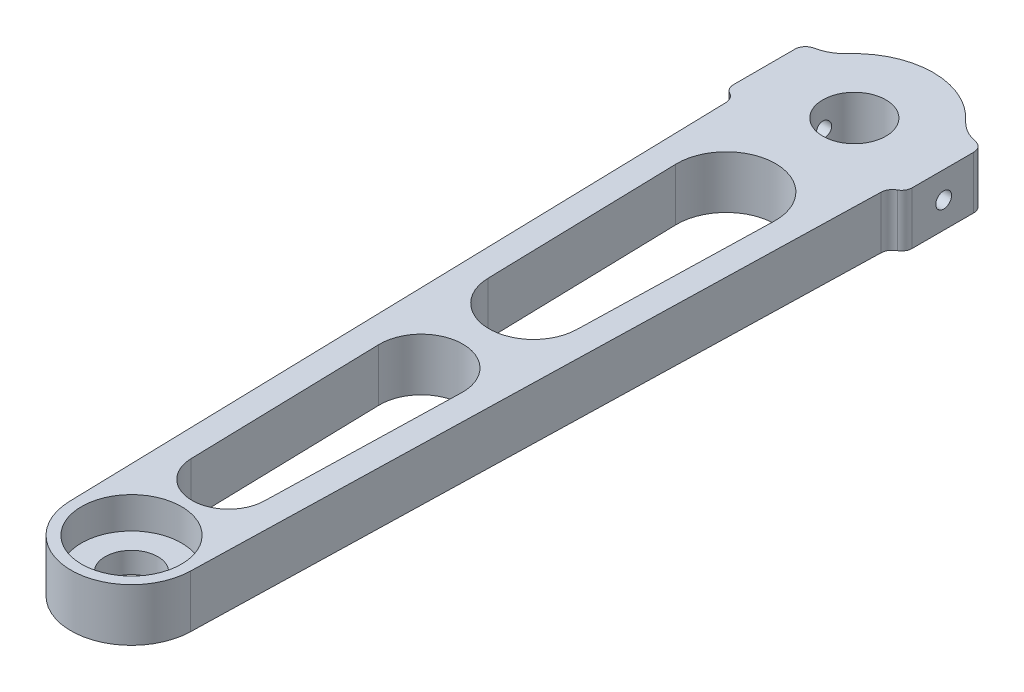
from build123d import *

# Parameters (mm, degrees)
SKETCH1_R           = 6
SKETCH1_R_2         = 5
BOSS_EXTRUDE1_DEPTH = 10
SKETCH2_R           = 9.5
CUT_EXTRUDE1_DEPTH  = 6
CUT_EXTRUDE3_DEPTH  = 11
FILLET1_R           = 2
M4_TAPPED_HOLE1_D   = 3


with BuildPart() as part:
    # Sketch1 → Boss-Extrude1 (new body)
    with BuildSketch(Plane(origin=(0, 0, 0), x_dir=(1, 0, 0), z_dir=(0, 1, 0))):
        with BuildLine():
            Line((-14.758368201, -9.680542044), (-11.496273776, -137.792727273))
            ThreePointArc((-11.496273776, -137.792727273), (0, -149), (11.496273776, -137.792727273))
            Line((11.496273776, -137.792727273), (14.758368201, -9.680542044))
            ThreePointArc((14.758368201, -9.680542044), (15.433257, -8.135337646), (16.995139708, -7.5))
            Line((16.995139708, -7.5), (16.995139708, 7.5))
            ThreePointArc((16.995139708, 7.5), (13.895638119, 8.122041636), (11.276155185, 9.891831188))
            ThreePointArc((11.276155185, 9.891831188), (0.004561048, 14.999999307), (-11.270137484, 9.898686836))
            ThreePointArc((-11.270137484, 9.898686836), (-13.891539017, 8.123905388), (-16.995139708, 7.5))
            Line((-16.995139708, 7.5), (-16.995139708, -7.5))
            ThreePointArc((-16.995139708, -7.5), (-15.433257, -8.135337646), (-14.758368201, -9.680542044))
        make_face()
        Circle(SKETCH1_R, mode=Mode.SUBTRACT)
        with Locations((0, -137.5)):
            Circle(SKETCH1_R_2, mode=Mode.SUBTRACT)
    extrude(amount=BOSS_EXTRUDE1_DEPTH)

    # Sketch2 → Cut-Extrude1 (cut)
    with BuildSketch(Plane(origin=(0, 10, 0), x_dir=(1, 0, 0), z_dir=(0, 1, 0))):
        with Locations((0, -137.5)):
            Circle(SKETCH2_R)
    extrude(amount=-CUT_EXTRUDE1_DEPTH, mode=Mode.SUBTRACT)

    # Sketch4 → Cut-Extrude3 (cut, through all)
    with BuildSketch(Plane(origin=(0, 0, 0), x_dir=(1, 0, 0), z_dir=(0, 1, 0))):
        with BuildLine():
            Line((-9.376393506, -24.618181818), (-8.443776056, -61.244852893))
            ThreePointArc((-8.443776056, -61.244852893), (0, -69.476363636), (8.443776056, -61.244852893))
            Line((8.443776056, -61.244852893), (9.376393506, -24.618181818))
            ThreePointArc((9.376393506, -24.618181818), (0, -15), (-9.376393506, -24.618181818))
        make_face()
        with BuildLine():
            Line((-7.90050824, -82.580601653), (-6.96789079, -119.207272727))
            ThreePointArc((-6.96789079, -119.207272727), (0, -126), (6.96789079, -119.207272727))
            Line((6.96789079, -119.207272727), (7.90050824, -82.580601653))
            ThreePointArc((7.90050824, -82.580601653), (0, -74.476363636), (-7.90050824, -82.580601653))
        make_face()
    extrude(amount=CUT_EXTRUDE3_DEPTH, mode=Mode.SUBTRACT)

    # Fillet1
    fillet1_edges = [part.edges().sort_by_distance(p)[0] for p in [
        (-16.995139708, 5, 7.5),
        (-16.995139708, 5, -7.5),
        (16.995139708, 5, -7.5),
        (16.995139708, 5, 7.5),
    ]]
    fillet(fillet1_edges, radius=FILLET1_R)

    # M4 Tapped Hole1 (through all)
    with Locations(Plane.ZY.offset(16.995139708)):
        with Locations((0, 5)):
            Hole(M4_TAPPED_HOLE1_D / 2)


solid = part.part
